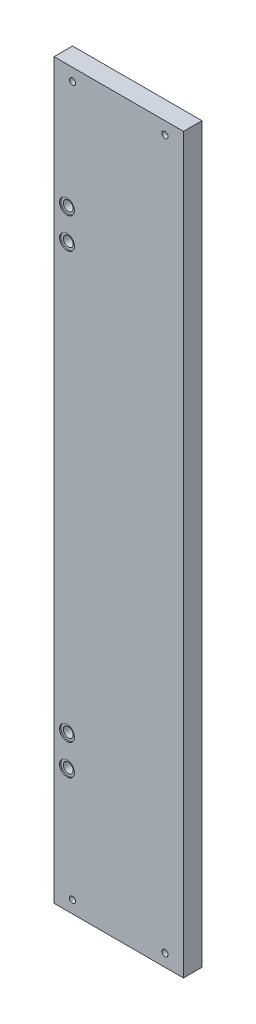
from build123d import *

# Parameters (mm, degrees)
SKETCH_1_W               = 105
SKETCH_1_H               = 595
EXTRUDE_1_DEPTH          = 15
SKETCH_2_R               = 4
CUT_EXTRUDE_2_DEPTH      = 303.469006677
SKETCH_2_5_R             = 2.5
CUT_EXTRUDE_3_DEPTH      = 303.469006677
MIRROR_3_COPY_1_SKETCH_R = 2.5
MIRROR_3_COPY_1_DEPTH    = 303.469006677
MIRROR_3_COPY_2_SKETCH_R = 2.5
MIRROR_3_COPY_2_DEPTH    = 303.469006677
SKETCH_3_R               = 6
CUT_EXTRUDE_4_DEPTH      = 1


with BuildPart() as part:
    # ｽｹｯﾁ1 → ﾎﾞｽ - 押し出し1 (new body)
    with BuildSketch(Plane.XY):
        Rectangle(SKETCH_1_W, SKETCH_1_H)
    extrude(amount=EXTRUDE_1_DEPTH)

    # ｽｹｯﾁ2 → ｶｯﾄ - 押し出し2 (cut, through all)
    with BuildSketch(Plane.XY.offset(15)):
        with Locations((-42, 197.5)):
            Circle(SKETCH_2_R)
        with Locations((-42, 172.5)):
            Circle(SKETCH_2_R)
    cut_extrude_2 = extrude(amount=-CUT_EXTRUDE_2_DEPTH, mode=Mode.SUBTRACT)

    # ｽｹｯﾁ2<5> → ｶｯﾄ - 押し出し3 (cut, through all)
    with BuildSketch(Plane.XY.offset(15)):
        with Locations((-37.5, 287.5)):
            Circle(SKETCH_2_5_R)
    cut_extrude_3 = extrude(amount=-CUT_EXTRUDE_3_DEPTH, mode=Mode.SUBTRACT)

    # ﾐﾗｰ1: ｶｯﾄ - 押し出し3 across plane
    add(cut_extrude_3.mirror(Plane.ZX), mode=Mode.SUBTRACT)

    # ﾐﾗｰ2: ｶｯﾄ - 押し出し2 across plane
    add(cut_extrude_2.mirror(Plane.ZX), mode=Mode.SUBTRACT)

    # ﾐﾗｰ3 copy 1 sketch → ﾐﾗｰ3 copy 1 (cut, through all)
    with BuildSketch(Plane(origin=(0, 0, 15), x_dir=(-1, 0, 0), z_dir=(0, 0, 1))):
        with Locations((-37.5, 287.5)):
            Circle(MIRROR_3_COPY_1_SKETCH_R)
    extrude(amount=-MIRROR_3_COPY_1_DEPTH, mode=Mode.SUBTRACT)

    # ﾐﾗｰ3 copy 2 sketch → ﾐﾗｰ3 copy 2 (cut, through all)
    with BuildSketch(Plane(origin=(0, 0, 15), x_dir=(-1, 0, 0), z_dir=(0, 0, 1))):
        with Locations((-37.5, -287.5)):
            Circle(MIRROR_3_COPY_2_SKETCH_R)
    extrude(amount=-MIRROR_3_COPY_2_DEPTH, mode=Mode.SUBTRACT)

    # ｽｹｯﾁ3 → ｶｯﾄ - 押し出し4 (cut)
    with BuildSketch(Plane.XY.offset(15)):
        with Locations((-42, 197.5)):
            Circle(SKETCH_3_R)
        with Locations((-42, 172.5)):
            Circle(SKETCH_3_R)
    cut_extrude_4 = extrude(amount=-CUT_EXTRUDE_4_DEPTH, mode=Mode.SUBTRACT)

    # ﾐﾗｰ4: ｶｯﾄ - 押し出し4 across plane
    add(cut_extrude_4.mirror(Plane.ZX), mode=Mode.SUBTRACT)


solid = part.part
